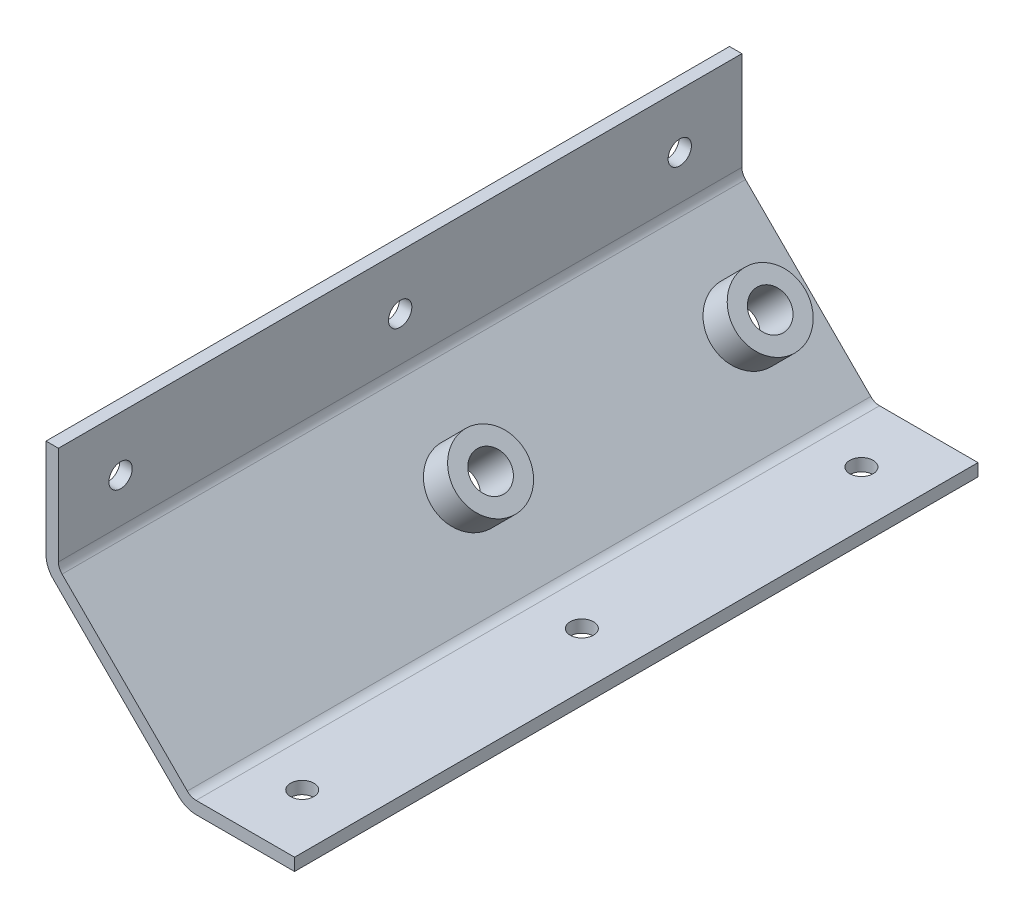
from build123d import *

# Parameters (mm, degrees)
EXTRUDE1_DEPTH     = 139.7
SKETCH2_R          = 2.3876
CUT_EXTRUDE1_DEPTH = 2.539999999
SKETCH3_R          = 2.3876
CUT_EXTRUDE2_DEPTH = 2.54
SKETCH4_R          = 3.81
CUT_EXTRUDE3_DEPTH = 2.539999999
SKETCH5_R          = 7.1755
SKETCH5_R_2        = 3.81
EXTRUDE2_DEPTH     = 6.985
FILLET1_R          = 2.54
FILLET2_R          = 5.08


with BuildPart() as part:
    # Sketch1 → Extrude1 (new body)
    with BuildSketch(Plane.XY):
        Polygon((5980.833305588, -6626.860000001), (6002.006203139, -6626.860000001), (6002.006203139, -6629.4), (5979.781203139, -6629.4), (5951.206203139, -6600.825), (5951.206203139, -6578.6), (5953.746203139, -6578.6), (5953.746203139, -6599.772897553), (5967.289754364, -6613.316448778), align=None)
    extrude(amount=EXTRUDE1_DEPTH)

    # Sketch2 → Cut-Extrude1 (cut)
    with BuildSketch(Plane.XZ.offset(6629.4)):
        with Locations(Location((5990.881003139, 127, 0), (0, 0, 270))):
            Circle(SKETCH2_R)
        with Locations(Location((5990.881003139, 69.85, 0), (0, 0, 270))):
            Circle(SKETCH2_R)
        with Locations(Location((5990.881003139, 12.7, 0), (0, 0, 270))):
            Circle(SKETCH2_R)
    extrude(amount=-CUT_EXTRUDE1_DEPTH, mode=Mode.SUBTRACT)

    # Sketch3 → Cut-Extrude2 (cut)
    with BuildSketch(Plane.ZY.offset(-5951.206203139)):
        with Locations((127, -6589.7252)):
            Circle(SKETCH3_R)
        with Locations((69.85, -6589.7252)):
            Circle(SKETCH3_R)
        with Locations((12.7, -6589.7252)):
            Circle(SKETCH3_R)
    extrude(amount=-CUT_EXTRUDE2_DEPTH, mode=Mode.SUBTRACT)

    # Sketch4 → Cut-Extrude3 (cut)
    with BuildSketch(Plane(origin=(-324.80939843, -324.80939843, 0), x_dir=(0, 0, 1), z_dir=(-0.7071067811865477, -0.7071067811865475, 0))):
        with Locations(Location((69.85, -8895.831957677, 0), (0, 0, 270))):
            Circle(SKETCH4_R)
        with Locations(Location((12.7, -8895.831957677, 0), (0, 0, 270))):
            Circle(SKETCH4_R)
    extrude(amount=-CUT_EXTRUDE3_DEPTH, mode=Mode.SUBTRACT)

    # Sketch5 → Extrude2 (add)
    with BuildSketch(Plane(origin=(-323.013347207, -323.013347207, 0), x_dir=(0, 0, -1), z_dir=(0.7071067811865477, 0.7071067811865475, 0))):
        with Locations(Location((-69.85, -8895.831957677, 0), (0, 0, 270))):
            Circle(SKETCH5_R)
        with Locations(Location((-69.85, -8895.831957677, 0), (0, 0, 270))):
            Circle(SKETCH5_R_2, mode=Mode.SUBTRACT)
        with Locations(Location((-12.7, -8895.831957677, 0), (0, 0, 270))):
            Circle(SKETCH5_R)
        with Locations(Location((-12.7, -8895.831957677, 0), (0, 0, 270))):
            Circle(SKETCH5_R_2, mode=Mode.SUBTRACT)
    extrude(amount=EXTRUDE2_DEPTH)

    # Fillet1
    fillet1_edges = [part.edges().sort_by_distance(p)[0] for p in [
        (5980.833305588, -6626.860000001, 69.85),
        (5953.746203139, -6599.772897553, 69.85),
    ]]
    fillet(fillet1_edges, radius=FILLET1_R)

    # Fillet2
    fillet2_edges = [part.edges().sort_by_distance(p)[0] for p in [
        (5979.781203139, -6629.4, 69.85),
        (5951.206203139, -6600.825, 69.85),
    ]]
    fillet(fillet2_edges, radius=FILLET2_R)


solid = part.part
